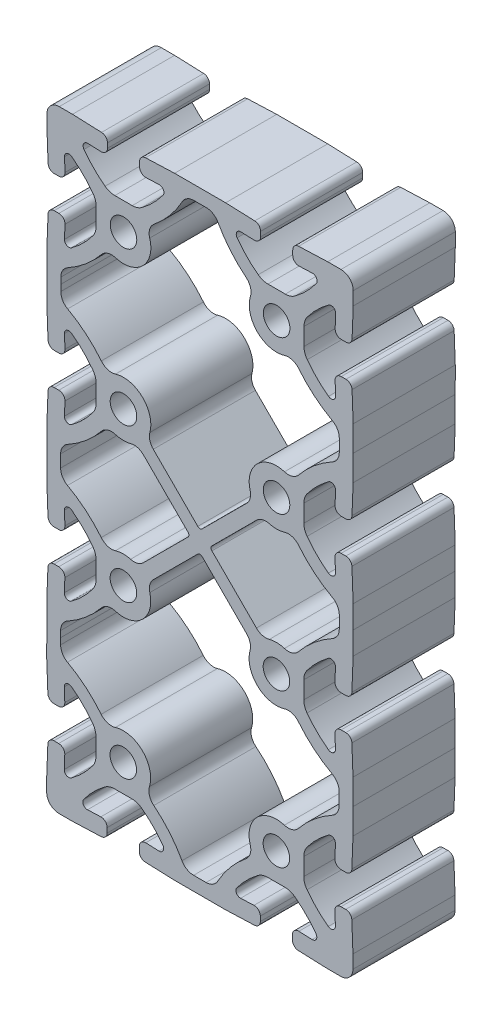
from build123d import *

# Parameters (mm, degrees)
EXTRUDE1_DEPTH = 25.4


with BuildPart() as part:
    # Sketch1 → Extrude1 (new body)
    with BuildSketch(Plane.XY):
        with BuildLine():
            Line((29.188507398, -14.697505022), (32.50933012, -14.570353897))
            ThreePointArc((32.50933012, -14.570353897), (33.624722204, -14.995443388), (34.091639714, -16.093982698))
            Line((34.091639714, -16.093982698), (34.091068344, -17.263260729))
            ThreePointArc((34.091068344, -17.263260729), (33.66486313, -18.319598331), (32.625378301, -18.785400119))
            Line((32.625378301, -18.785400119), (25.390688147, -19.062409486))
            Line((25.390688147, -19.062409486), (19.040688906, -19.059306546))
            Line((19.040688906, -19.059306546), (12.690689664, -19.056203606))
            Line((12.690689664, -19.056203606), (5.456273687, -18.772123881))
            ThreePointArc((5.456273687, -18.772123881), (4.417244585, -18.305306423), (3.992071937, -17.248552793))
            Line((3.992071937, -17.248552793), (3.992643307, -16.079274763))
            ThreePointArc((3.992643307, -16.079274763), (4.460634201, -14.981192298), (5.576441194, -14.557193086))
            Line((5.576441194, -14.557193086), (8.897138064, -14.687589604))
            ThreePointArc((8.897138064, -14.687589604), (9.921129024, -14.100114765), (9.838212232, -12.922486225))
            ThreePointArc((9.838212232, -12.922486225), (7.4093885, -10.070396661), (4.58156594, -7.61336203))
            ThreePointArc((4.58156594, -7.61336203), (3.43345211, -7.015090915), (2.155441071, -6.808254073))
            Line((2.155441071, -6.808254073), (-0.003326352, -6.807199187))
            Line((-0.003326352, -6.807199187), (-2.162093775, -6.806144301))
            ThreePointArc((-2.162093775, -6.806144301), (-3.440306345, -7.011732039), (-4.58900432, -7.608880813))
            ThreePointArc((-4.58900432, -7.608880813), (-7.419226799, -10.063150628), (-9.850836729, -12.912865132))
            ThreePointArc((-9.850836729, -12.912865132), (-9.934904382, -14.090412074), (-8.911488053, -14.678887382))
            Line((-8.911488053, -14.678887382), (-5.590665331, -14.551736257))
            ThreePointArc((-5.590665331, -14.551736257), (-4.475273247, -14.976825748), (-4.008355737, -16.075365058))
            Line((-4.008355737, -16.075365058), (-4.008927107, -17.244643089))
            ThreePointArc((-4.008927107, -17.244643089), (-4.435132321, -18.300980691), (-5.47461715, -18.766782479))
            Line((-5.47461715, -18.766782479), (-12.709307304, -19.043791846))
            Line((-12.709307304, -19.043791846), (-16.01130691, -19.042178317))
            ThreePointArc((-16.01130691, -19.042178317), (-18.166131883, -18.14838672), (-19.057817134, -15.99268927))
            Line((-19.057817134, -15.99268927), (-19.056203606, -12.690689664))
            Line((-19.056203606, -12.690689664), (-18.772123881, -5.456273687))
            ThreePointArc((-18.772123881, -5.456273687), (-18.305306423, -4.417244585), (-17.248552793, -3.992071937))
            Line((-17.248552793, -3.992071937), (-16.079274763, -3.992643307))
            ThreePointArc((-16.079274763, -3.992643307), (-14.981192298, -4.460634201), (-14.557193086, -5.576441194))
            Line((-14.557193086, -5.576441194), (-14.687589604, -8.897138064))
            ThreePointArc((-14.687589604, -8.897138064), (-14.100114765, -9.921129024), (-12.922486225, -9.838212232))
            ThreePointArc((-12.922486225, -9.838212232), (-10.070396661, -7.4093885), (-7.61336203, -4.58156594))
            ThreePointArc((-7.61336203, -4.58156594), (-7.015090915, -3.43345211), (-6.808254073, -2.155441071))
            Line((-6.808254073, -2.155441071), (-6.807199187, 0.003326352))
            Line((-6.807199187, 0.003326352), (-6.806144301, 2.162093775))
            ThreePointArc((-6.806144301, 2.162093775), (-7.011732039, 3.440306345), (-7.608880813, 4.58900432))
            ThreePointArc((-7.608880813, 4.58900432), (-10.063150628, 7.419226799), (-12.912865132, 9.850836729))
            ThreePointArc((-12.912865132, 9.850836729), (-14.090412074, 9.934904382), (-14.678887382, 8.911488053))
            Line((-14.678887382, 8.911488053), (-14.551736257, 5.590665331))
            ThreePointArc((-14.551736257, 5.590665331), (-14.976825748, 4.475273247), (-16.075365058, 4.008355737))
            Line((-16.075365058, 4.008355737), (-17.244643089, 4.008927107))
            ThreePointArc((-17.244643089, 4.008927107), (-18.300980691, 4.435132321), (-18.766782479, 5.47461715))
            Line((-18.766782479, 5.47461715), (-19.043791846, 12.709307304))
            Line((-19.043791846, 12.709307304), (-19.040688493, 19.060150545))
            Line((-19.040688493, 19.060150545), (-19.034481789, 25.410991512))
            Line((-19.034481789, 25.410991512), (-18.746866987, 32.645267809))
            ThreePointArc((-18.746866987, 32.645267809), (-18.279541861, 33.684068676), (-17.222580596, 34.108724888))
            Line((-17.222580596, 34.108724888), (-16.053302984, 34.107582148))
            ThreePointArc((-16.053302984, 34.107582148), (-14.955449335, 33.63905473), (-14.531995415, 32.523040683))
            Line((-14.531995415, 32.523040683), (-14.664014582, 29.202407927))
            ThreePointArc((-14.664014582, 29.202407927), (-14.077040189, 28.178130019), (-12.899371272, 28.26047135))
            ThreePointArc((-12.899371272, 28.26047135), (-10.046095199, 30.687901113), (-7.587679041, 33.514522701))
            ThreePointArc((-7.587679041, 33.514522701), (-6.988846969, 34.662344047), (-6.781385649, 35.940253862))
            Line((-6.781385649, 35.940253862), (-6.779275877, 38.099020512))
            Line((-6.779275877, 38.099020512), (-6.777166105, 40.257787162))
            ThreePointArc((-6.777166105, 40.257787162), (-6.982129218, 41.53610004), (-7.578716606, 42.685089675))
            ThreePointArc((-7.578716606, 42.685089675), (-10.031603135, 45.5165111), (-12.880129087, 47.949513259))
            ThreePointArc((-12.880129087, 47.949513259), (-14.057634809, 48.034156312), (-14.646610142, 47.011027665))
            Line((-14.646610142, 47.011027665), (-14.521081758, 43.690143207))
            ThreePointArc((-14.521081758, 43.690143207), (-14.946716237, 42.574958977), (-16.045483576, 42.108578327))
            Line((-16.045483576, 42.108578327), (-17.214761188, 42.109721067))
            ThreePointArc((-17.214761188, 42.109721067), (-18.270890398, 42.536442411), (-18.736184184, 43.576154731))
            Line((-18.736184184, 43.576154731), (-19.035164639, 51.485756617))
            Line((-19.035164639, 51.485756617), (-19.040688493, 57.137890478))
            Line((-19.040688493, 57.137890478), (-19.029640789, 62.790016242))
            Line((-19.029640789, 62.790016242), (-18.722930394, 70.699322156))
            ThreePointArc((-18.722930394, 70.699322156), (-18.256620715, 71.738579246), (-17.200074973, 72.164268227))
            Line((-17.200074973, 72.164268227), (-16.030796802, 72.164268227))
            ThreePointArc((-16.030796802, 72.164268227), (-14.932485784, 71.69681397), (-14.507941381, 70.581214299))
            Line((-14.507941381, 70.581214299), (-14.636715219, 67.260454106))
            ThreePointArc((-14.636715219, 67.260454106), (-14.048740075, 66.236750339), (-12.871152193, 66.320242571))
            ThreePointArc((-12.871152193, 66.320242571), (-10.020249819, 68.750459693), (-7.564597303, 71.57948255))
            ThreePointArc((-7.564597303, 71.57948255), (-6.966887287, 72.72788859), (-6.760674973, 74.006000547))
            Line((-6.760674973, 74.006000547), (-6.760674973, 76.164768227))
            Line((-6.760674973, 76.164768227), (-6.760674973, 78.323535908))
            ThreePointArc((-6.760674973, 78.323535908), (-6.966887287, 79.601647865), (-7.564597303, 80.750053904))
            ThreePointArc((-7.564597303, 80.750053904), (-10.020249819, 83.579076762), (-12.871152193, 86.009293883))
            ThreePointArc((-12.871152193, 86.009293883), (-14.048740075, 86.092786115), (-14.636715219, 85.069082349))
            Line((-14.636715219, 85.069082349), (-14.507941381, 81.748322156))
            ThreePointArc((-14.507941381, 81.748322156), (-14.932485784, 80.632722485), (-16.030796802, 80.165268227))
            Line((-16.030796802, 80.165268227), (-17.200074973, 80.165268227))
            ThreePointArc((-17.200074973, 80.165268227), (-18.256620715, 80.590957209), (-18.722930394, 81.630214299))
            Line((-18.722930394, 81.630214299), (-19.003474973, 88.864768227))
            Line((-19.003474973, 88.864768227), (-19.003474973, 95.215612227))
            Line((-19.003474973, 95.215612227), (-19.00037162, 101.566455469))
            Line((-19.00037162, 101.566455469), (-18.716291896, 108.800871445))
            ThreePointArc((-18.716291896, 108.800871445), (-18.249474438, 109.839900548), (-17.192720808, 110.265073195))
            Line((-17.192720808, 110.265073195), (-16.023442777, 110.264501825))
            ThreePointArc((-16.023442777, 110.264501825), (-14.925360312, 109.796510931), (-14.5013611, 108.680703939))
            Line((-14.5013611, 108.680703939), (-14.631757618, 105.360007068))
            ThreePointArc((-14.631757618, 105.360007068), (-14.044282779, 104.336016109), (-12.86665424, 104.4189329))
            ThreePointArc((-12.86665424, 104.4189329), (-10.014564675, 106.847756632), (-7.557530045, 109.675579193))
            ThreePointArc((-7.557530045, 109.675579193), (-6.95925893, 110.823693023), (-6.752422088, 112.101704061))
            Line((-6.752422088, 112.101704061), (-6.751367202, 114.260471484))
            Line((-6.751367202, 114.260471484), (-6.750312316, 116.419238907))
            ThreePointArc((-6.750312316, 116.419238907), (-6.955900054, 117.697451478), (-7.553048827, 118.846149452))
            ThreePointArc((-7.553048827, 118.846149452), (-10.007318642, 121.676371931), (-12.857033146, 124.107981861))
            ThreePointArc((-12.857033146, 124.107981861), (-14.034580088, 124.192049514), (-14.623055397, 123.168633185))
            Line((-14.623055397, 123.168633185), (-14.495904271, 119.847810463))
            ThreePointArc((-14.495904271, 119.847810463), (-14.920993763, 118.732418379), (-16.019533073, 118.26550087))
            Line((-16.019533073, 118.26550087), (-17.188811103, 118.26607224))
            ThreePointArc((-17.188811103, 118.26607224), (-18.245148706, 118.692277453), (-18.710950494, 119.731762282))
            Line((-18.710950494, 119.731762282), (-18.98795986, 126.966452436))
            Line((-18.98795986, 126.966452436), (-18.986346331, 130.268452042))
            ThreePointArc((-18.986346331, 130.268452042), (-18.092554734, 132.423277015), (-15.936857284, 133.314962267))
            Line((-15.936857284, 133.314962267), (-12.634857678, 133.313348738))
            Line((-12.634857678, 133.313348738), (-5.400441702, 133.029269013))
            ThreePointArc((-5.400441702, 133.029269013), (-4.361412599, 132.562451556), (-3.936239952, 131.505697925))
            Line((-3.936239952, 131.505697925), (-3.936811322, 130.336419895))
            ThreePointArc((-3.936811322, 130.336419895), (-4.404802215, 129.23833743), (-5.520609208, 128.814338218))
            Line((-5.520609208, 128.814338218), (-8.841306079, 128.944734736))
            ThreePointArc((-8.841306079, 128.944734736), (-9.865297038, 128.357259897), (-9.782380247, 127.179631358))
            ThreePointArc((-9.782380247, 127.179631358), (-7.353556514, 124.327541793), (-4.525733954, 121.870507163))
            ThreePointArc((-4.525733954, 121.870507163), (-3.377620124, 121.272236048), (-2.099609086, 121.065399206))
            Line((-2.099609086, 121.065399206), (0.059158337, 121.06434432))
            Line((0.059158337, 121.06434432), (2.21792576, 121.063289434))
            ThreePointArc((2.21792576, 121.063289434), (3.496138331, 121.268877172), (4.644836305, 121.866025945))
            ThreePointArc((4.644836305, 121.866025945), (7.475058784, 124.32029576), (9.906668715, 127.170010264))
            ThreePointArc((9.906668715, 127.170010264), (9.990736367, 128.347557206), (8.967320038, 128.936032515))
            Line((8.967320038, 128.936032515), (5.646497316, 128.808881389))
            ThreePointArc((5.646497316, 128.808881389), (4.531105233, 129.233970881), (4.064187723, 130.332510191))
            Line((4.064187723, 130.332510191), (4.064759093, 131.501788221))
            ThreePointArc((4.064759093, 131.501788221), (4.490964307, 132.558125824), (5.530449135, 133.023927612))
            Line((5.530449135, 133.023927612), (12.765139289, 133.300936978))
            Line((12.765139289, 133.300936978), (19.115138531, 133.297834038))
            Line((19.115138531, 133.297834038), (25.465137773, 133.294731098))
            Line((25.465137773, 133.294731098), (32.699553749, 133.010651373))
            ThreePointArc((32.699553749, 133.010651373), (33.738582852, 132.543833916), (34.163755499, 131.487080285))
            Line((34.163755499, 131.487080285), (34.163184129, 130.317802255))
            ThreePointArc((34.163184129, 130.317802255), (33.695193236, 129.21971979), (32.579386243, 128.795720578))
            Line((32.579386243, 128.795720578), (29.258689372, 128.926117096))
            ThreePointArc((29.258689372, 128.926117096), (28.234698413, 128.338642257), (28.317615204, 127.161013718))
            ThreePointArc((28.317615204, 127.161013718), (30.746438937, 124.308924153), (33.574261497, 121.851889523))
            ThreePointArc((33.574261497, 121.851889523), (34.722375327, 121.253618408), (36.000386365, 121.046781566))
            Line((36.000386365, 121.046781566), (38.159153788, 121.04572668))
            Line((38.159153788, 121.04572668), (40.317921211, 121.044671794))
            ThreePointArc((40.317921211, 121.044671794), (41.596133782, 121.250259532), (42.744831756, 121.847408305))
            ThreePointArc((42.744831756, 121.847408305), (45.575054235, 124.30167812), (48.006664166, 127.151392624))
            ThreePointArc((48.006664166, 127.151392624), (48.090731818, 128.328939566), (47.06731549, 128.917414875))
            Line((47.06731549, 128.917414875), (43.746492768, 128.790263749))
            ThreePointArc((43.746492768, 128.790263749), (42.631100684, 129.215353241), (42.164183174, 130.313892551))
            Line((42.164183174, 130.313892551), (42.164754544, 131.483170581))
            ThreePointArc((42.164754544, 131.483170581), (42.590959758, 132.539508184), (43.630444587, 133.005309972))
            Line((43.630444587, 133.005309972), (50.86513474, 133.282319338))
            Line((50.86513474, 133.282319338), (54.167134346, 133.280705809))
            ThreePointArc((54.167134346, 133.280705809), (56.32195932, 132.386914212), (57.213644571, 130.231216762))
            Line((57.213644571, 130.231216762), (57.212031042, 126.929217156))
            Line((57.212031042, 126.929217156), (56.927951318, 119.69480118))
            ThreePointArc((56.927951318, 119.69480118), (56.46113386, 118.655772077), (55.40438023, 118.23059943))
            Line((55.40438023, 118.23059943), (54.235102199, 118.2311708))
            ThreePointArc((54.235102199, 118.2311708), (53.137019734, 118.699161693), (52.713020523, 119.814968686))
            Line((52.713020523, 119.814968686), (52.84341704, 123.135665557))
            ThreePointArc((52.84341704, 123.135665557), (52.255942201, 124.159656516), (51.078313662, 124.076739725))
            ThreePointArc((51.078313662, 124.076739725), (48.226224098, 121.647915992), (45.769189467, 118.820093432))
            ThreePointArc((45.769189467, 118.820093432), (45.170918352, 117.671979602), (44.96408151, 116.393968564))
            Line((44.96408151, 116.393968564), (44.963026624, 114.235201141))
            Line((44.963026624, 114.235201141), (44.961971738, 112.076433718))
            ThreePointArc((44.961971738, 112.076433718), (45.167559476, 110.798221147), (45.764708249, 109.649523173))
            ThreePointArc((45.764708249, 109.649523173), (48.218978065, 106.819300694), (51.068692568, 104.387690763))
            ThreePointArc((51.068692568, 104.387690763), (52.24623951, 104.303623111), (52.834714819, 105.327039439))
            Line((52.834714819, 105.327039439), (52.707563693, 108.647862161))
            ThreePointArc((52.707563693, 108.647862161), (53.132653185, 109.763254245), (54.231192495, 110.230171755))
            Line((54.231192495, 110.230171755), (55.400470525, 110.229600385))
            ThreePointArc((55.400470525, 110.229600385), (56.456808128, 109.803395171), (56.922609916, 108.763910342))
            Line((56.922609916, 108.763910342), (57.199619282, 101.529220189))
            Line((57.199619282, 101.529220189), (57.19651593, 95.178376947))
            Line((57.19651593, 95.178376947), (57.190309226, 88.82753598))
            Line((57.190309226, 88.82753598), (56.902694424, 81.593259684))
            ThreePointArc((56.902694424, 81.593259684), (56.435369298, 80.554458816), (55.378408032, 80.129802605))
            Line((55.378408032, 80.129802605), (54.209130421, 80.130945345))
            ThreePointArc((54.209130421, 80.130945345), (53.111276772, 80.599472762), (52.687822852, 81.71548681))
            Line((52.687822852, 81.71548681), (52.819842019, 85.036119566))
            ThreePointArc((52.819842019, 85.036119566), (52.232867625, 86.060397473), (51.055198709, 85.978056142))
            ThreePointArc((51.055198709, 85.978056142), (48.201922636, 83.550626379), (45.743506477, 80.724004791))
            ThreePointArc((45.743506477, 80.724004791), (45.144674406, 79.576183445), (44.937213086, 78.29827363))
            Line((44.937213086, 78.29827363), (44.935103314, 76.139506981))
            Line((44.935103314, 76.139506981), (44.932993542, 73.980740331))
            ThreePointArc((44.932993542, 73.980740331), (45.137956655, 72.702427452), (45.734544043, 71.553437817))
            ThreePointArc((45.734544043, 71.553437817), (48.187430572, 68.722016392), (51.035956524, 66.289014233))
            ThreePointArc((51.035956524, 66.289014233), (52.213462246, 66.20437118), (52.802437579, 67.227499827))
            Line((52.802437579, 67.227499827), (52.676909195, 70.548384285))
            ThreePointArc((52.676909195, 70.548384285), (53.102543674, 71.663568515), (54.201311013, 72.129949166))
            Line((54.201311013, 72.129949166), (55.370588625, 72.128806426))
            ThreePointArc((55.370588625, 72.128806426), (56.426717835, 71.702085081), (56.892011621, 70.662372762))
            Line((56.892011621, 70.662372762), (57.190992075, 62.752770875))
            Line((57.190992075, 62.752770875), (57.19651593, 57.100637014))
            Line((57.19651593, 57.100637014), (57.185468226, 51.448511251))
            Line((57.185468226, 51.448511251), (56.87875783, 43.539205336))
            ThreePointArc((56.87875783, 43.539205336), (56.412448152, 42.499948246), (55.355902409, 42.074259265))
            Line((55.355902409, 42.074259265), (54.186624239, 42.074259265))
            ThreePointArc((54.186624239, 42.074259265), (53.088313221, 42.541713522), (52.663768818, 43.657313194))
            Line((52.663768818, 43.657313194), (52.792542655, 46.978073387))
            ThreePointArc((52.792542655, 46.978073387), (52.204567511, 48.001777153), (51.02697963, 47.918284921))
            ThreePointArc((51.02697963, 47.918284921), (48.176077255, 45.488067799), (45.720424739, 42.659044942))
            ThreePointArc((45.720424739, 42.659044942), (45.122714724, 41.510638903), (44.916502409, 40.232526946))
            Line((44.916502409, 40.232526946), (44.916502409, 38.073759265))
            Line((44.916502409, 38.073759265), (44.916502409, 35.914991584))
            ThreePointArc((44.916502409, 35.914991584), (45.122714724, 34.636879627), (45.720424739, 33.488473588))
            ThreePointArc((45.720424739, 33.488473588), (48.176077255, 30.659450731), (51.02697963, 28.229233609))
            ThreePointArc((51.02697963, 28.229233609), (52.204567511, 28.145741377), (52.792542655, 29.169445143))
            Line((52.792542655, 29.169445143), (52.663768818, 32.490205336))
            ThreePointArc((52.663768818, 32.490205336), (53.088313221, 33.605805008), (54.186624239, 34.073259265))
            Line((54.186624239, 34.073259265), (55.355902409, 34.073259265))
            ThreePointArc((55.355902409, 34.073259265), (56.412448152, 33.647570284), (56.87875783, 32.608313194))
            Line((56.87875783, 32.608313194), (57.159302409, 25.373759265))
            Line((57.159302409, 25.373759265), (57.159302409, 19.022915265))
            Line((57.159302409, 19.022915265), (57.156199057, 12.672072024))
            Line((57.156199057, 12.672072024), (56.872119332, 5.437656047))
            ThreePointArc((56.872119332, 5.437656047), (56.405301875, 4.398626945), (55.348548244, 3.973454297))
            Line((55.348548244, 3.973454297), (54.179270214, 3.974025667))
            ThreePointArc((54.179270214, 3.974025667), (53.081187749, 4.442016561), (52.657188537, 5.557823554))
            Line((52.657188537, 5.557823554), (52.787585055, 8.878520424))
            ThreePointArc((52.787585055, 8.878520424), (52.200110216, 9.902511384), (51.022481677, 9.819594592))
            ThreePointArc((51.022481677, 9.819594592), (48.170392112, 7.39077086), (45.713357481, 4.5629483))
            ThreePointArc((45.713357481, 4.5629483), (45.115086367, 3.41483447), (44.908249525, 2.136823431))
            Line((44.908249525, 2.136823431), (44.907194639, -0.021943992))
            Line((44.907194639, -0.021943992), (44.906139752, -2.180711415))
            ThreePointArc((44.906139752, -2.180711415), (45.111727491, -3.458923985), (45.708876264, -4.607621959))
            ThreePointArc((45.708876264, -4.607621959), (48.163146079, -7.437844439), (51.012860583, -9.869454369))
            ThreePointArc((51.012860583, -9.869454369), (52.190407525, -9.953522022), (52.778882834, -8.930105693))
            Line((52.778882834, -8.930105693), (52.651731708, -5.609282971))
            ThreePointArc((52.651731708, -5.609282971), (53.076821199, -4.493890887), (54.17536051, -4.026973377))
            Line((54.17536051, -4.026973377), (55.34463854, -4.027544747))
            ThreePointArc((55.34463854, -4.027544747), (56.400976143, -4.453749961), (56.86677793, -5.49323479))
            Line((56.86677793, -5.49323479), (57.143787297, -12.727924944))
            Line((57.143787297, -12.727924944), (57.142173768, -16.029924549))
            ThreePointArc((57.142173768, -16.029924549), (56.248382171, -18.184749523), (54.092684721, -19.076434774))
            Line((54.092684721, -19.076434774), (50.790685115, -19.074821246))
            Line((50.790685115, -19.074821246), (43.556269139, -18.790741521))
            ThreePointArc((43.556269139, -18.790741521), (42.517240036, -18.323924063), (42.092067389, -17.267170433))
            Line((42.092067389, -17.267170433), (42.092638759, -16.097892403))
            ThreePointArc((42.092638759, -16.097892403), (42.560629652, -14.999809938), (43.676436645, -14.575810726))
            Line((43.676436645, -14.575810726), (46.997133516, -14.706207244))
            ThreePointArc((46.997133516, -14.706207244), (48.021124475, -14.118732405), (47.938207683, -12.941103865))
            ThreePointArc((47.938207683, -12.941103865), (45.509383951, -10.089014301), (42.681561391, -7.63197967))
            ThreePointArc((42.681561391, -7.63197967), (41.533447561, -7.033708555), (40.255436523, -6.826871713))
            Line((40.255436523, -6.826871713), (38.0966691, -6.825816827))
            Line((38.0966691, -6.825816827), (35.937901677, -6.824761941))
            ThreePointArc((35.937901677, -6.824761941), (34.659689106, -7.030349679), (33.510991132, -7.627498453))
            ThreePointArc((33.510991132, -7.627498453), (30.680768653, -10.081768268), (28.249158722, -12.931482772))
            ThreePointArc((28.249158722, -12.931482772), (28.16509107, -14.109029714), (29.188507398, -14.697505022))
        make_face()
        with BuildLine():
            Line((19.615208818, 54.138034434), (30.688903867, 43.056125903))
            ThreePointArc((30.688903867, 43.056125903), (31.544209179, 41.570938823), (31.539847667, 39.857080949))
            ThreePointArc((31.539847667, 39.857080949), (31.361800495, 38.973309018), (31.302102409, 38.073759265))
            ThreePointArc((31.302102409, 38.073759265), (31.820269656, 35.468756604), (33.295885128, 33.260341984))
            ThreePointArc((33.295885128, 33.260341984), (35.504299748, 31.784726511), (38.109302409, 31.266559265))
            ThreePointArc((38.109302409, 31.266559265), (39.111262199, 31.34070287), (40.091395419, 31.561518549))
            ThreePointArc((40.091395419, 31.561518549), (42.020494324, 31.559633161), (43.619324673, 30.48020384))
            ThreePointArc((43.619324673, 30.48020384), (47.469242105, 26.565107977), (51.998517425, 23.460997006))
            ThreePointArc((51.998517425, 23.460997006), (53.246485078, 22.248575958), (53.704902409, 20.570111895))
            Line((53.704902409, 20.570111895), (53.704902409, 19.023759265))
            Line((53.704902409, 19.023759265), (53.704146781, 17.477406819))
            ThreePointArc((53.704146781, 17.477406819), (53.244909319, 15.799166964), (51.996349364, 14.587355883))
            ThreePointArc((51.996349364, 14.587355883), (47.465557755, 11.485458521), (43.613727663, 7.572244395))
            ThreePointArc((43.613727663, 7.572244395), (42.01437004, 6.493596475), (40.085270444, 6.492653745))
            ThreePointArc((40.085270444, 6.492653745), (39.105245242, 6.713948342), (38.103321803, 6.788581547))
            ThreePointArc((38.103321803, 6.788581547), (35.49806625, 6.271687303), (33.288930831, 4.797151152))
            ThreePointArc((33.288930831, 4.797151152), (31.812236388, 2.589457858), (31.292796264, -0.015291288))
            ThreePointArc((31.292796264, -0.015291288), (31.36645025, -1.017287189), (31.586786959, -1.997528194))
            ThreePointArc((31.586786959, -1.997528194), (31.583958913, -3.926625948), (30.50374845, -5.52492864))
            ThreePointArc((30.50374845, -5.52492864), (26.586771785, -9.372932493), (23.480447944, -13.900690443))
            ThreePointArc((23.480447944, -13.900690443), (22.267417219, -15.148065494), (20.588729351, -15.605662586))
            Line((20.588729351, -15.605662586), (19.042376905, -15.604906958))
            Line((19.042376905, -15.604906958), (17.496024459, -15.60415133))
            ThreePointArc((17.496024459, -15.60415133), (15.817784604, -15.144913868), (14.605973523, -13.896353913))
            ThreePointArc((14.605973523, -13.896353913), (11.504076161, -9.365562303), (7.590862035, -5.513732211))
            ThreePointArc((7.590862035, -5.513732211), (6.512214115, -3.914374589), (6.511271385, -1.985274993))
            ThreePointArc((6.511271385, -1.985274993), (6.732565982, -1.005249791), (6.807199187, -0.003326352))
            ThreePointArc((6.807199187, -0.003326352), (6.290304943, 2.601929202), (4.815768792, 4.81106462))
            ThreePointArc((4.815768792, 4.81106462), (2.608075498, 6.287759063), (0.003326352, 6.807199187))
            ThreePointArc((0.003326352, 6.807199187), (-0.998669549, 6.733545201), (-1.978910554, 6.513208492))
            ThreePointArc((-1.978910554, 6.513208492), (-3.908008308, 6.516036538), (-5.506311, 7.596247002))
            ThreePointArc((-5.506311, 7.596247002), (-9.354314853, 11.513223667), (-13.882072803, 14.619547507))
            ThreePointArc((-13.882072803, 14.619547507), (-15.129447854, 15.832578232), (-15.587044946, 17.511266101))
            Line((-15.587044946, 17.511266101), (-15.586289318, 19.057618546))
            Line((-15.586289318, 19.057618546), (-15.584778062, 20.603970438))
            ThreePointArc((-15.584778062, 20.603970438), (-15.12472058, 22.281985686), (-13.87556862, 23.493186511))
            ThreePointArc((-13.87556862, 23.493186511), (-9.343261803, 26.592869522), (-5.489519971, 30.504200977))
            ThreePointArc((-5.489519971, 30.504200977), (-3.889635456, 31.582067239), (-1.960535629, 31.582067311))
            ThreePointArc((-1.960535629, 31.582067311), (-0.980618681, 31.360293849), (0.021268169, 31.28517106))
            ThreePointArc((0.021268169, 31.28517106), (2.626775993, 31.80079218), (4.836631683, 33.274248656))
            ThreePointArc((4.836631683, 33.274248656), (6.314404743, 35.481220097), (6.835117621, 38.085715107))
            ThreePointArc((6.835117621, 38.085715107), (6.776298697, 38.985322774), (6.599115324, 39.869268288))
            ThreePointArc((6.599115324, 39.869268288), (6.596428774, 41.583129607), (7.453185156, 43.067480084))
            Line((7.453185156, 43.067480084), (18.537705309, 54.138560958))
            ThreePointArc((18.537705309, 54.138560958), (19.076566092, 54.361418761), (19.615208818, 54.138034434))
        make_face(mode=Mode.SUBTRACT)
        with BuildLine():
            Line((19.113450532, 129.84343445), (20.659802977, 129.842678822))
            ThreePointArc((20.659802977, 129.842678822), (22.338042833, 129.38344136), (23.549853914, 128.134881405))
            ThreePointArc((23.549853914, 128.134881405), (26.651751276, 123.604089796), (30.564965402, 119.752259704))
            ThreePointArc((30.564965402, 119.752259704), (31.643613322, 118.152902081), (31.644556052, 116.223802485))
            ThreePointArc((31.644556052, 116.223802485), (31.423261455, 115.243777284), (31.348628249, 114.241853844))
            ThreePointArc((31.348628249, 114.241853844), (31.865522494, 111.636598291), (33.340058645, 109.427462872))
            ThreePointArc((33.340058645, 109.427462872), (35.547751939, 107.950768429), (38.152501085, 107.431328305))
            ThreePointArc((38.152501085, 107.431328305), (39.154496985, 107.504982291), (40.134737991, 107.725319))
            ThreePointArc((40.134737991, 107.725319), (42.063835744, 107.722490954), (43.662138436, 106.642280491))
            ThreePointArc((43.662138436, 106.642280491), (47.51014229, 102.725303826), (52.037900239, 99.618979985))
            ThreePointArc((52.037900239, 99.618979985), (53.285275291, 98.40594926), (53.742872383, 96.727261392))
            Line((53.742872383, 96.727261392), (53.742116755, 95.180908946))
            Line((53.742116755, 95.180908946), (53.740605498, 93.634557054))
            ThreePointArc((53.740605498, 93.634557054), (53.280548016, 91.956541806), (52.031396056, 90.745340981))
            ThreePointArc((52.031396056, 90.745340981), (47.49908924, 87.64565797), (43.645347408, 83.734326516))
            ThreePointArc((43.645347408, 83.734326516), (42.045462893, 82.656460254), (40.116363066, 82.656460182))
            ThreePointArc((40.116363066, 82.656460182), (39.136446118, 82.878233644), (38.134559267, 82.953356432))
            ThreePointArc((38.134559267, 82.953356432), (35.529051444, 82.437735312), (33.319195754, 80.964278836))
            ThreePointArc((33.319195754, 80.964278836), (31.841422694, 78.757307396), (31.320709816, 76.152812386))
            ThreePointArc((31.320709816, 76.152812386), (31.37952874, 75.253204719), (31.556712113, 74.369259204))
            ThreePointArc((31.556712113, 74.369259204), (31.559398663, 72.655397886), (30.70264228, 71.171047408))
            Line((30.70264228, 71.171047408), (19.618122128, 60.099966535))
            ThreePointArc((19.618122128, 60.099966535), (19.079261345, 59.877108731), (18.540618619, 60.100493059))
            Line((18.540618619, 60.100493059), (7.46692357, 71.182401589))
            ThreePointArc((7.46692357, 71.182401589), (6.611618258, 72.667588669), (6.61597977, 74.381446544))
            ThreePointArc((6.61597977, 74.381446544), (6.794026942, 75.265218474), (6.853725027, 76.164768227))
            ThreePointArc((6.853725027, 76.164768227), (6.335557781, 78.769770888), (4.859942308, 80.978185508))
            ThreePointArc((4.859942308, 80.978185508), (2.651527688, 82.453800981), (0.046525027, 82.971968227))
            ThreePointArc((0.046525027, 82.971968227), (-0.955434762, 82.897824622), (-1.935567983, 82.677008943))
            ThreePointArc((-1.935567983, 82.677008943), (-3.864666888, 82.678894332), (-5.463497236, 83.758323652))
            ThreePointArc((-5.463497236, 83.758323652), (-9.313414668, 87.673419515), (-13.842689988, 90.777530487))
            ThreePointArc((-13.842689988, 90.777530487), (-15.090657641, 91.989951535), (-15.549074973, 93.668415597))
            Line((-15.549074973, 93.668415597), (-15.549074973, 95.214768227))
            Line((-15.549074973, 95.214768227), (-15.548319344, 96.761120673))
            ThreePointArc((-15.548319344, 96.761120673), (-15.089081883, 98.439360528), (-13.840521927, 99.65117161))
            ThreePointArc((-13.840521927, 99.65117161), (-9.309730318, 102.753068972), (-5.457900226, 106.666283097))
            ThreePointArc((-5.457900226, 106.666283097), (-3.858542603, 107.744931017), (-1.929443007, 107.745873748))
            ThreePointArc((-1.929443007, 107.745873748), (-0.949417806, 107.524579151), (0.052505634, 107.449945945))
            ThreePointArc((0.052505634, 107.449945945), (2.657761187, 107.96684019), (4.866896606, 109.44137634))
            ThreePointArc((4.866896606, 109.44137634), (6.343591049, 111.649069634), (6.863031173, 114.253818781))
            ThreePointArc((6.863031173, 114.253818781), (6.789377186, 115.255814681), (6.569040477, 116.236055686))
            ThreePointArc((6.569040477, 116.236055686), (6.571868524, 118.16515344), (7.652078987, 119.763456132))
            ThreePointArc((7.652078987, 119.763456132), (11.569055652, 123.611459985), (14.675379493, 128.139217935))
            ThreePointArc((14.675379493, 128.139217935), (15.888410218, 129.386592986), (17.567098086, 129.844190079))
            Line((17.567098086, 129.844190079), (19.113450532, 129.84343445))
        make_face(mode=Mode.SUBTRACT)
        with BuildLine():
            Line((53.74510313, 58.632296885), (53.739098368, 55.560195333))
            ThreePointArc((53.739098368, 55.560195333), (53.277401175, 53.882630502), (52.0270661, 52.672651056))
            ThreePointArc((52.0270661, 52.672651056), (47.487007462, 49.573455972), (43.626409011, 45.660283065))
            ThreePointArc((43.626409011, 45.660283065), (42.02666739, 44.583512398), (40.098298085, 44.583895058))
            ThreePointArc((40.098298085, 44.583895058), (38.218854293, 44.88007767), (36.330852046, 44.64453442))
            ThreePointArc((36.330852046, 44.64453442), (34.616991408, 44.641443626), (33.132438891, 45.497849873))
            Line((33.132438891, 45.497849873), (22.059573851, 56.578927779))
            ThreePointArc((22.059573851, 56.578927779), (21.83658902, 57.117915714), (22.060100499, 57.656685467))
            Line((22.060100499, 57.656685467), (33.143789831, 68.726936528))
            ThreePointArc((33.143789831, 68.726936528), (34.629178609, 69.581891508), (36.343035407, 69.577125752))
            ThreePointArc((36.343035407, 69.577125752), (38.230806555, 69.339737463), (40.110538911, 69.634083146))
            ThreePointArc((40.110538911, 69.634083146), (42.038907669, 69.632581203), (43.637596193, 68.554247616))
            ThreePointArc((43.637596193, 68.554247616), (47.496135039, 64.635826139), (52.03543092, 61.531451516))
            ThreePointArc((52.03543092, 61.531451516), (53.287376417, 60.316055187), (53.74510313, 58.632296885))
        make_face(mode=Mode.SUBTRACT)
        with BuildLine():
            Line((5.012037606, 45.511590964), (16.095726938, 56.581842025))
            ThreePointArc((16.095726938, 56.581842025), (16.319238416, 57.120611778), (16.096253586, 57.659599713))
            Line((16.096253586, 57.659599713), (5.023388546, 68.740677619))
            ThreePointArc((5.023388546, 68.740677619), (3.538836029, 69.597083867), (1.824975391, 69.593993072))
            ThreePointArc((1.824975391, 69.593993072), (-0.063026856, 69.358449823), (-1.942470649, 69.654632435))
            ThreePointArc((-1.942470649, 69.654632435), (-3.870839954, 69.655015095), (-5.470581574, 68.578244427))
            ThreePointArc((-5.470581574, 68.578244427), (-9.331180025, 64.66507152), (-13.871238663, 61.565876436))
            ThreePointArc((-13.871238663, 61.565876436), (-15.121573738, 60.35589699), (-15.583270931, 58.678332159))
            Line((-15.583270931, 58.678332159), (-15.589275693, 55.606230607))
            ThreePointArc((-15.589275693, 55.606230607), (-15.13154898, 53.922472305), (-13.879603484, 52.707075976))
            ThreePointArc((-13.879603484, 52.707075976), (-9.340307603, 49.602701353), (-5.481768756, 45.684279876))
            ThreePointArc((-5.481768756, 45.684279876), (-3.883080232, 44.605946289), (-1.954711474, 44.604444346))
            ThreePointArc((-1.954711474, 44.604444346), (-0.074979119, 44.898790029), (1.81279203, 44.66140174))
            ThreePointArc((1.81279203, 44.66140174), (3.526648828, 44.656635984), (5.012037606, 45.511590964))
        make_face(mode=Mode.SUBTRACT)
        with BuildLine():
            ThreePointArc((0.024693815, 34.790369386), (1.28855955, 35.040484108), (2.360504474, 35.755220459))
            ThreePointArc((2.360504474, 35.755220459), (3.07733469, 36.825766307), (3.329919295, 38.089140752))
            ThreePointArc((3.329919295, 38.089140752), (3.079804573, 39.353006487), (2.365068222, 40.424951412))
            ThreePointArc((2.365068222, 40.424951412), (1.294522374, 41.141781627), (0.031147929, 41.394366232))
            ThreePointArc((0.031147929, 41.394366232), (-1.232717806, 41.14425151), (-2.304662731, 40.42951516))
            ThreePointArc((-2.304662731, 40.42951516), (-3.021492946, 39.358969312), (-3.274077551, 38.095594866))
            ThreePointArc((-3.274077551, 38.095594866), (-3.023962829, 36.831729131), (-2.309226479, 35.759784207))
            ThreePointArc((-2.309226479, 35.759784207), (-1.23868063, 35.042953991), (0.024693815, 34.790369386))
        make_face(mode=Mode.SUBTRACT)
        with BuildLine():
            ThreePointArc((38.109302409, 34.771759265), (39.372923103, 35.023109049), (40.444169001, 35.738892674))
            ThreePointArc((40.444169001, 35.738892674), (41.159952626, 36.810138571), (41.411302409, 38.073759265))
            ThreePointArc((41.411302409, 38.073759265), (41.159952626, 39.337379959), (40.444169001, 40.408625856))
            ThreePointArc((40.444169001, 40.408625856), (39.372923103, 41.124409481), (38.109302409, 41.375759265))
            ThreePointArc((38.109302409, 41.375759265), (36.845681716, 41.124409481), (35.774435818, 40.408625856))
            ThreePointArc((35.774435818, 40.408625856), (35.058652193, 39.337379959), (34.807302409, 38.073759265))
            ThreePointArc((34.807302409, 38.073759265), (35.058652193, 36.810138571), (35.774435818, 35.738892674))
            ThreePointArc((35.774435818, 35.738892674), (36.845681716, 35.023109049), (38.109302409, 34.771759265))
        make_face(mode=Mode.SUBTRACT)
        with BuildLine():
            ThreePointArc((-2.33600725, -2.333725376), (-1.265111249, -3.050032381), (-0.001613529, -3.301999606))
            ThreePointArc((-0.001613529, -3.301999606), (1.262129837, -3.051267323), (2.333725376, -2.33600725))
            ThreePointArc((2.333725376, -2.33600725), (3.050032381, -1.265111249), (3.301999606, -0.001613529))
            ThreePointArc((3.301999606, -0.001613529), (3.051267323, 1.262129837), (2.33600725, 2.333725376))
            ThreePointArc((2.33600725, 2.333725376), (1.265111249, 3.050032381), (0.001613529, 3.301999606))
            ThreePointArc((0.001613529, 3.301999606), (-1.262129837, 3.051267323), (-2.333725376, 2.33600725))
            ThreePointArc((-2.333725376, 2.33600725), (-3.050032381, 1.265111249), (-3.301999606, 0.001613529))
            ThreePointArc((-3.301999606, 0.001613529), (-3.051267323, -1.262129837), (-2.33600725, -2.333725376))
        make_face(mode=Mode.SUBTRACT)
        with BuildLine():
            ThreePointArc((38.098381922, -3.320617246), (39.362125288, -3.069884963), (40.433720827, -2.35462489))
            ThreePointArc((40.433720827, -2.35462489), (41.150027833, -1.283728889), (41.401995057, -0.020231169))
            ThreePointArc((41.401995057, -0.020231169), (41.151262774, 1.243512197), (40.436002701, 2.315107736))
            ThreePointArc((40.436002701, 2.315107736), (39.3651067, 3.031414741), (38.10160898, 3.283381966))
            ThreePointArc((38.10160898, 3.283381966), (36.837865615, 3.032649683), (35.766270076, 2.31738961))
            ThreePointArc((35.766270076, 2.31738961), (35.04996307, 1.246493609), (34.797995845, -0.017004111))
            ThreePointArc((34.797995845, -0.017004111), (35.048728128, -1.280747477), (35.763988201, -2.352343016))
            ThreePointArc((35.763988201, -2.352343016), (36.834884202, -3.068650021), (38.098381922, -3.320617246))
        make_face(mode=Mode.SUBTRACT)
        with BuildLine():
            ThreePointArc((0.054218457, 110.955145527), (1.317961822, 111.205877809), (2.389557361, 111.921137882))
            ThreePointArc((2.389557361, 111.921137882), (3.105864367, 112.992033883), (3.357831591, 114.255531604))
            ThreePointArc((3.357831591, 114.255531604), (3.107099308, 115.519274969), (2.391839235, 116.590870508))
            ThreePointArc((2.391839235, 116.590870508), (1.320943235, 117.307177514), (0.057445514, 117.559144738))
            ThreePointArc((0.057445514, 117.559144738), (-1.206297851, 117.308412455), (-2.27789339, 116.593152382))
            ThreePointArc((-2.27789339, 116.593152382), (-2.994200396, 115.522256381), (-3.24616762, 114.258758661))
            ThreePointArc((-3.24616762, 114.258758661), (-2.995435337, 112.995015296), (-2.280175264, 111.923419757))
            ThreePointArc((-2.280175264, 111.923419757), (-1.209279264, 111.207112751), (0.054218457, 110.955145527))
        make_face(mode=Mode.SUBTRACT)
        with BuildLine():
            ThreePointArc((38.154213908, 110.936527887), (39.417957273, 111.187260169), (40.489552812, 111.902520242))
            ThreePointArc((40.489552812, 111.902520242), (41.205859818, 112.973416243), (41.457827043, 114.236913964))
            ThreePointArc((41.457827043, 114.236913964), (41.20709476, 115.500657329), (40.491834687, 116.572252868))
            ThreePointArc((40.491834687, 116.572252868), (39.420938686, 117.288559874), (38.157440966, 117.540527098))
            ThreePointArc((38.157440966, 117.540527098), (36.8936976, 117.289794815), (35.822102061, 116.574534742))
            ThreePointArc((35.822102061, 116.574534742), (35.105795055, 115.503638741), (34.853827831, 114.240141021))
            ThreePointArc((34.853827831, 114.240141021), (35.104560114, 112.976397656), (35.819820187, 111.904802117))
            ThreePointArc((35.819820187, 111.904802117), (36.890716188, 111.188495111), (38.154213908, 110.936527887))
        make_face(mode=Mode.SUBTRACT)
        with BuildLine():
            ThreePointArc((0.046525027, 72.862768227), (1.310145721, 73.114118011), (2.381391619, 73.829901636))
            ThreePointArc((2.381391619, 73.829901636), (3.097175244, 74.901147534), (3.348525027, 76.164768227))
            ThreePointArc((3.348525027, 76.164768227), (3.097175244, 77.428388921), (2.381391619, 78.499634819))
            ThreePointArc((2.381391619, 78.499634819), (1.310145721, 79.215418444), (0.046525027, 79.466768227))
            ThreePointArc((0.046525027, 79.466768227), (-1.217095666, 79.215418444), (-2.288341564, 78.499634819))
            ThreePointArc((-2.288341564, 78.499634819), (-3.004125189, 77.428388921), (-3.255474973, 76.164768227))
            ThreePointArc((-3.255474973, 76.164768227), (-3.004125189, 74.901147534), (-2.288341564, 73.829901636))
            ThreePointArc((-2.288341564, 73.829901636), (-1.217095666, 73.114118011), (0.046525027, 72.862768227))
        make_face(mode=Mode.SUBTRACT)
        with BuildLine():
            ThreePointArc((38.124679508, 72.84416126), (39.388545243, 73.094275982), (40.460490167, 73.809012333))
            ThreePointArc((40.460490167, 73.809012333), (41.177320383, 74.879558181), (41.429904988, 76.142932626))
            ThreePointArc((41.429904988, 76.142932626), (41.179790266, 77.406798361), (40.465053915, 78.478743285))
            ThreePointArc((40.465053915, 78.478743285), (39.394508067, 79.195573501), (38.131133622, 79.448158106))
            ThreePointArc((38.131133622, 79.448158106), (36.867267887, 79.198043384), (35.795322962, 78.483307034))
            ThreePointArc((35.795322962, 78.483307034), (35.078492747, 77.412761185), (34.825908142, 76.14938674))
            ThreePointArc((34.825908142, 76.14938674), (35.076022864, 74.885521005), (35.790759214, 73.813576081))
            ThreePointArc((35.790759214, 73.813576081), (36.861305063, 73.096745865), (38.124679508, 72.84416126))
        make_face(mode=Mode.SUBTRACT)
    extrude(amount=EXTRUDE1_DEPTH)


solid = part.part
